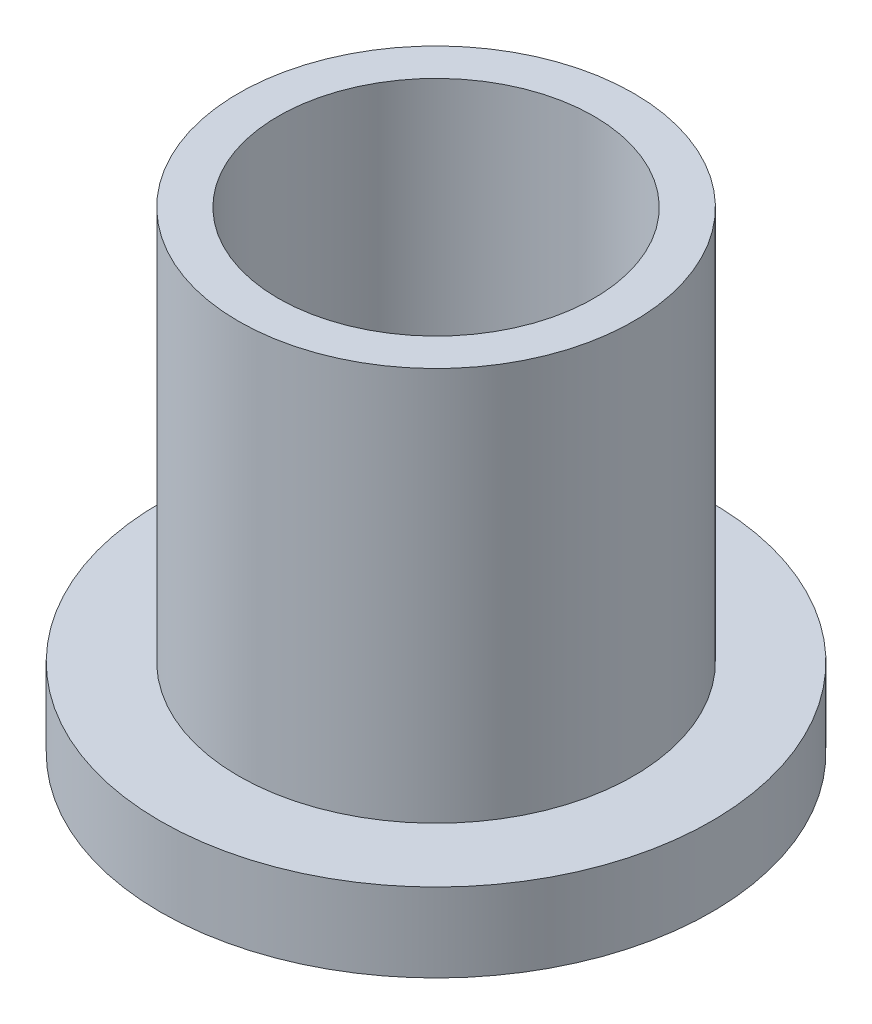
from build123d import *

# Parameters (mm, degrees)
SKETCH2_R           = 7.9629
SKETCH2_R_2         = 6.3627
BOSS_EXTRUDE1_DEPTH = 19.05
SKETCH3_R           = 11.1125
SKETCH3_R_2         = 7.9629
BOSS_EXTRUDE2_DEPTH = 3.175


with BuildPart() as part:
    # Sketch2 → Boss-Extrude1 (new body)
    with BuildSketch(Plane(origin=(0, 0, 0), x_dir=(1, 0, 0), z_dir=(0, 1, 0))):
        Circle(SKETCH2_R)
        Circle(SKETCH2_R_2, mode=Mode.SUBTRACT)
    extrude(amount=BOSS_EXTRUDE1_DEPTH)

    # Sketch3 → Boss-Extrude2 (add)
    with BuildSketch(Plane(origin=(0, 0, 0), x_dir=(1, 0, 0), z_dir=(0, 1, 0))):
        Circle(SKETCH3_R)
        Circle(SKETCH3_R_2, mode=Mode.SUBTRACT)
    extrude(amount=BOSS_EXTRUDE2_DEPTH)


solid = part.part
